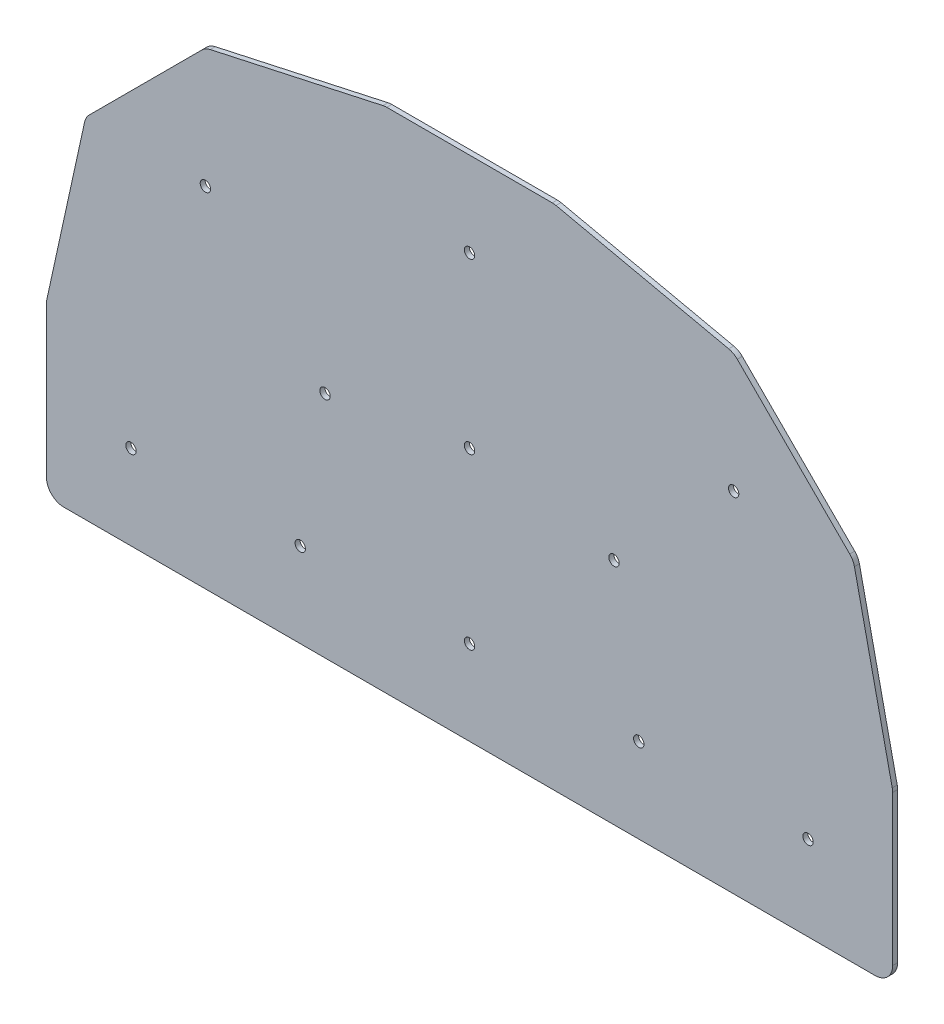
from build123d import *

# Parameters (mm, degrees)
SKETCH1_R           = 1.651
BOSS_EXTRUDE1_DEPTH = 1.5875


with BuildPart() as part:
    # Sketch1 → Boss-Extrude1 (new body)
    with BuildSketch(Plane(origin=(0, 0, 0), x_dir=(-1, 0, 0), z_dir=(0, 0, -1))):
        with BuildLine():
            Line((-129.38125, 0), (129.38125, 0))
            ThreePointArc((129.38125, 0), (133.310112053, 1.627387947), (134.9375, 5.55625))
            Line((134.9375, 5.55625), (134.9375, 53.373846086))
            ThreePointArc((134.9375, 53.373846086), (134.905262076, 53.971512085), (134.8089224, 54.562242647))
            Line((134.8089224, 54.562242647), (122.750794586, 109.634404323))
            ThreePointArc((122.750794586, 109.634404323), (122.197927005, 111.112127049), (121.251984239, 112.374869817))
            Line((121.251984239, 112.374869817), (85.387369836, 148.239484219))
            ThreePointArc((85.387369836, 148.239484219), (84.124627068, 149.185426985), (82.646904343, 149.738294567))
            Line((82.646904343, 149.738294567), (27.574742607, 161.796422401))
            ThreePointArc((27.574742607, 161.796422401), (26.984012045, 161.892762078), (26.386346045, 161.925000002))
            Line((26.386346045, 161.925000002), (-26.386346022, 161.925000002))
            ThreePointArc((-26.386346022, 161.925000002), (-26.984012021, 161.892762078), (-27.574742583, 161.796422402))
            Line((-27.574742583, 161.796422402), (-82.646904321, 149.738294575))
            ThreePointArc((-82.646904321, 149.738294575), (-84.124627046, 149.185426993), (-85.387369815, 148.239484227))
            Line((-85.387369815, 148.239484227), (-121.251984217, 112.374869825))
            ThreePointArc((-121.251984217, 112.374869825), (-122.197926983, 111.112127057), (-122.750794565, 109.634404332))
            Line((-122.750794565, 109.634404332), (-134.808922399, 54.562242596))
            ThreePointArc((-134.808922399, 54.562242596), (-134.905262076, 53.971512033), (-134.9375, 53.373846033))
            Line((-134.9375, 53.373846033), (-134.9375, 5.55625))
            ThreePointArc((-134.9375, 5.55625), (-133.310112053, 1.627387947), (-129.38125, 0))
        make_face()
        with Locations((-53.975, 26.9875)):
            Circle(SKETCH1_R, mode=Mode.SUBTRACT)
        with Locations((53.975, 26.9875)):
            Circle(SKETCH1_R, mode=Mode.SUBTRACT)
        with Locations((46.070544257, 73.058044257)):
            Circle(SKETCH1_R, mode=Mode.SUBTRACT)
        with Locations((84.236632771, 111.224132771)):
            Circle(SKETCH1_R, mode=Mode.SUBTRACT)
        with Locations((-46.070544257, 73.058044257)):
            Circle(SKETCH1_R, mode=Mode.SUBTRACT)
        with Locations((-84.236632771, 111.224132771)):
            Circle(SKETCH1_R, mode=Mode.SUBTRACT)
        with Locations((-107.95, 26.9875)):
            Circle(SKETCH1_R, mode=Mode.SUBTRACT)
        with Locations((107.95, 26.9875)):
            Circle(SKETCH1_R, mode=Mode.SUBTRACT)
        with Locations((0, 80.9625)):
            Circle(SKETCH1_R, mode=Mode.SUBTRACT)
        with Locations((0, 134.9375)):
            Circle(SKETCH1_R, mode=Mode.SUBTRACT)
        with Locations((0, 26.9875)):
            Circle(SKETCH1_R, mode=Mode.SUBTRACT)
    extrude(amount=-BOSS_EXTRUDE1_DEPTH)


solid = part.part
